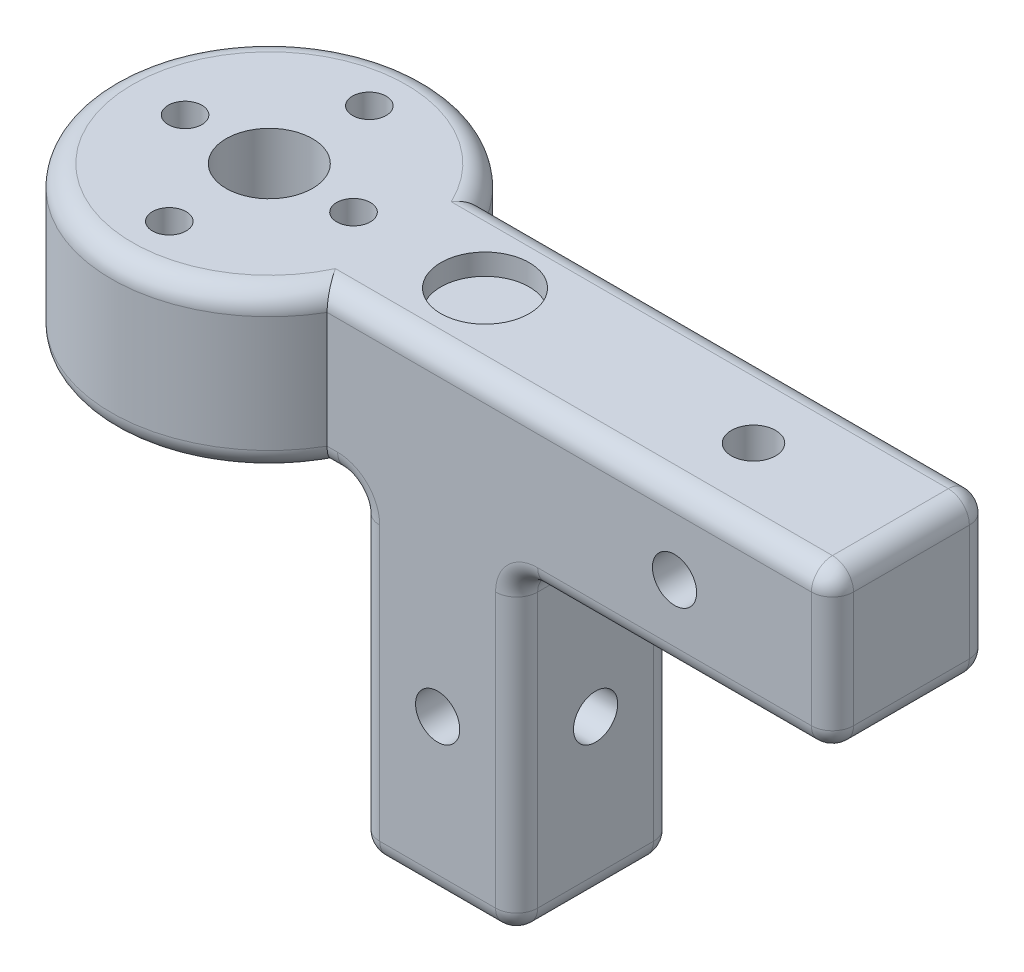
from build123d import *

# Parameters (mm, degrees)
BOSS_EXTRUDE1_DEPTH = 15
SKETCH2_R           = 4.1
SKETCH2_R_2         = 1.6
SKETCH2_R_3         = 2.1
TOP_GATEN_DEPTH     = 15
SKETCH3_W           = 15
SKETCH3_H           = 15
ONDER_EXTRUDE_DEPTH = 30
SKETCH4_R           = 2.1
Z_GATEN_DEPTH       = 15
SKETCH5_R           = 2.1
CUT_EXTRUDE3_DEPTH  = 15
SKETCH6_R           = 4.2
CUT_EXTRUDE4_DEPTH  = 2
FILLET2_R           = 2


with BuildPart() as part:
    # Sketch1 → Boss-Extrude1 (new body)
    with BuildSketch(Plane(origin=(0, 0, 0), x_dir=(1, 0, 0), z_dir=(0, 1, 0))):
        with BuildLine():
            Line((12.990381057, 7.5), (60.990381057, 7.5))
            Line((60.990381057, 7.5), (60.990381057, -7.5))
            Line((60.990381057, -7.5), (12.990381057, -7.5))
            ThreePointArc((12.990381057, -7.5), (-15, 0), (12.990381057, 7.5))
        make_face()
    extrude(amount=BOSS_EXTRUDE1_DEPTH)

    # Sketch2 → top-gaten (cut)
    with BuildSketch(Plane(origin=(0, 15, 0), x_dir=(1, 0, 0), z_dir=(0, 1, 0))):
        Circle(SKETCH2_R)
        with Locations((0, 9.5)):
            Circle(SKETCH2_R_2)
        with Locations((0, -9.5)):
            Circle(SKETCH2_R_2)
        with Locations((-8, 0)):
            Circle(SKETCH2_R_2)
        with Locations((8, 0)):
            Circle(SKETCH2_R_2)
        with Locations((45.990381057, 0)):
            Circle(SKETCH2_R_3)
    extrude(amount=-TOP_GATEN_DEPTH, mode=Mode.SUBTRACT)

    # Sketch3 → Onder-extrude (add)
    with BuildSketch(Plane.XZ):
        with Locations((23.490381057, 0)):
            Rectangle(SKETCH3_W, SKETCH3_H)
    extrude(amount=ONDER_EXTRUDE_DEPTH)

    # Sketch4 → Z-gaten (cut)
    with BuildSketch(Plane.XY.offset(7.5)):
        with Locations((45.990381057, 7.5)):
            Circle(SKETCH4_R)
        with Locations((23.490381057, -15)):
            Circle(SKETCH4_R)
    extrude(amount=-Z_GATEN_DEPTH, mode=Mode.SUBTRACT)

    # Sketch5 → Cut-Extrude3 (cut)
    with BuildSketch(Plane(origin=(30.990381057, 0, 0), x_dir=(0, 0, -1), z_dir=(1, 0, 0))):
        with Locations((0, -15)):
            Circle(SKETCH5_R)
    extrude(amount=-CUT_EXTRUDE3_DEPTH, mode=Mode.SUBTRACT)

    # Sketch6 → Cut-Extrude4 (cut)
    with BuildSketch(Plane(origin=(0, 15, 0), x_dir=(1, 0, 0), z_dir=(0, 1, 0))):
        with Locations((20.490381057, 0)):
            Circle(SKETCH6_R)
    extrude(amount=-CUT_EXTRUDE4_DEPTH, mode=Mode.SUBTRACT)

    # Fillet2
    fillet2_edges = [part.edges().sort_by_distance(p)[0] for p in [
        (60.990381057, 15, 0),
        (36.990381057, 15, -7.5),
        (-4.1, 0, 0),
        (-15, 15, 0),
        (14.490381057, 0, -7.5),
        (45.990381057, 0, 7.5),
        (15.990381057, 0, 0),
        (15.990381057, -15, 7.5),
        (15.990381057, -15, -7.5),
        (30.990381057, 0, 0),
        (30.990381057, -15, -7.5),
        (30.990381057, -15, 7.5),
        (15.990381057, -30, 0),
        (23.490381057, -30, -7.5),
        (30.990381057, -30, 0),
        (45.990381057, 0, -7.5),
        (23.490381057, -30, 7.5),
        (60.990381057, 0, 0),
        (14.490381057, 0, 7.5),
        (-15, 0, 0),
        (36.990381057, 15, 7.5),
        (60.990381057, 7.5, -7.5),
        (60.990381057, 7.5, 7.5),
    ]]
    fillet(fillet2_edges, radius=FILLET2_R)


solid = part.part
